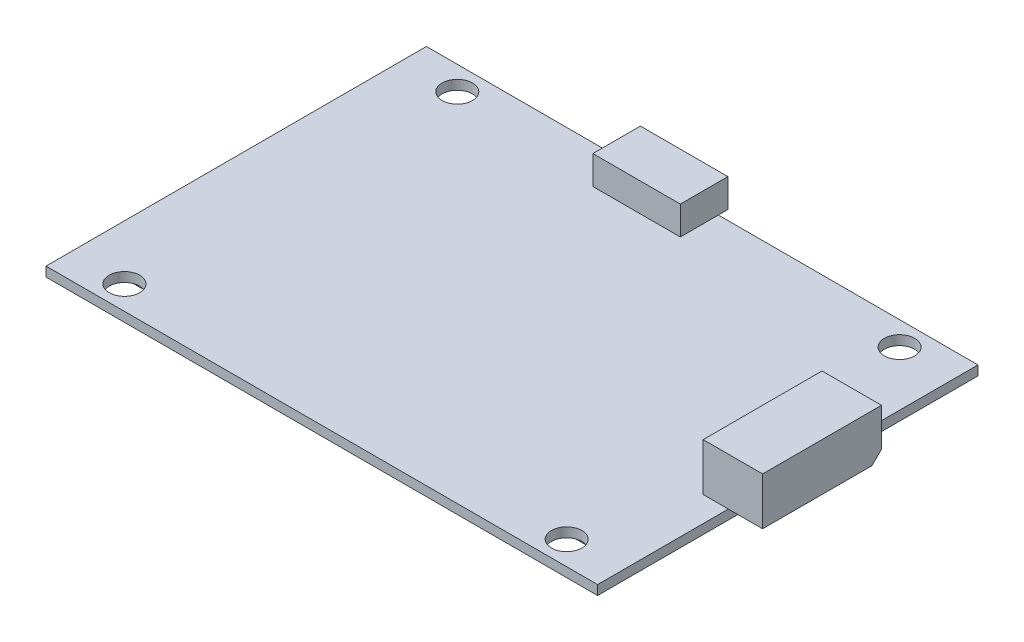
from build123d import *

# Parameters (mm, degrees)
SKETCH1_W           = 58
SKETCH1_H           = 40
BOSS_EXTRUDE1_DEPTH = 1
SKETCH2_W           = 6.25
SKETCH2_H           = 12.5
BOSS_EXTRUDE2_DEPTH = 5
CHAMFER1_SIZE       = 1
SKETCH3_W           = 9.2
SKETCH3_H           = 5
BOSS_EXTRUDE3_DEPTH = 3
SKETCH4_W           = 5
SKETCH4_H           = 6.6
BOSS_EXTRUDE4_DEPTH = 4
SKETCH5_R           = 1.6
CUT_EXTRUDE1_DEPTH  = 6


with BuildPart() as part:
    # Sketch1 → Boss-Extrude1 (new body)
    with BuildSketch(Plane(origin=(0, 0, 0), x_dir=(1, 0, 0), z_dir=(0, 1, 0))):
        Rectangle(SKETCH1_W, SKETCH1_H)
    extrude(amount=BOSS_EXTRUDE1_DEPTH)

    # Sketch2 → Boss-Extrude2 (add)
    with BuildSketch(Plane(origin=(0, 1, 0), x_dir=(1, 0, 0), z_dir=(0, 1, 0))):
        with Locations((29.475, 0)):
            Rectangle(SKETCH2_W, SKETCH2_H)
    extrude(amount=BOSS_EXTRUDE2_DEPTH)

    # Chamfer1
    chamfer1_edges = [part.edges().sort_by_distance(p)[0] for p in [
        (30.8, 1, -6.25),
    ]]
    chamfer(chamfer1_edges, length=CHAMFER1_SIZE)

    # Sketch3 → Boss-Extrude3 (add)
    with BuildSketch(Plane(origin=(0, 1, 0), x_dir=(1, 0, 0), z_dir=(0, 1, 0))):
        with Locations((-2.9, 18.5)):
            Rectangle(SKETCH3_W, SKETCH3_H)
    extrude(amount=BOSS_EXTRUDE3_DEPTH)

    # Sketch4 → Boss-Extrude4 (add)
    with BuildSketch(Plane.XZ):
        with Locations((-25.5, 8.7)):
            Rectangle(SKETCH4_W, SKETCH4_H)
        with Locations((-25.5, -8.9)):
            Rectangle(SKETCH4_W, SKETCH4_H)
        with Locations((20, 8.7)):
            Rectangle(SKETCH4_W, SKETCH4_H)
        with Locations((20, -8.9)):
            Rectangle(SKETCH4_W, SKETCH4_H)
    extrude(amount=BOSS_EXTRUDE4_DEPTH)

    # Sketch5 → Cut-Extrude1 (cut, through all)
    with BuildSketch(Plane(origin=(0, 1, 0), x_dir=(1, 0, 0), z_dir=(0, 1, 0))):
        with Locations((-23.25, 17.5)):
            Circle(SKETCH5_R)
        with Locations((-23.25, -17.5)):
            Circle(SKETCH5_R)
        with Locations((23.25, -17.5)):
            Circle(SKETCH5_R)
        with Locations((23.25, 17.5)):
            Circle(SKETCH5_R)
    extrude(amount=-CUT_EXTRUDE1_DEPTH, mode=Mode.SUBTRACT)


solid = part.part
